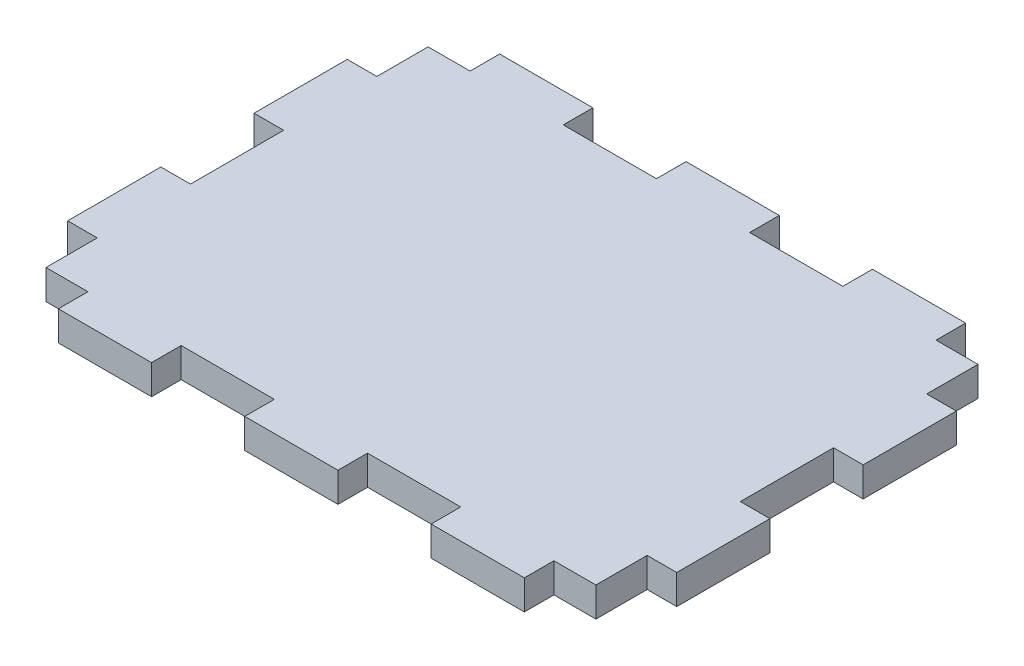
from build123d import *

# Parameters (mm, degrees)
SKETCH1_W           = 65.35
SKETCH1_H           = 47.35
BOSS_EXTRUDE1_DEPTH = 3.175
SKETCH2_W           = 4.5
SKETCH2_H           = 3.175
SKETCH2_W_2         = 3.175
SKETCH2_H_2         = 10
SKETCH2_W_3         = 10
CUT_EXTRUDE1_DEPTH  = 4.175


with BuildPart() as part:
    # Sketch1 → Boss-Extrude1 (new body)
    with BuildSketch(Plane(origin=(0, 0, 0), x_dir=(1, 0, 0), z_dir=(0, 1, 0))):
        with Locations((32.675, 23.675)):
            Rectangle(SKETCH1_W, SKETCH1_H)
    extrude(amount=BOSS_EXTRUDE1_DEPTH)

    # Sketch2 → Cut-Extrude1 (cut, through all)
    with BuildSketch(Plane.XZ):
        with Locations((59.925, -45.7625)):
            Rectangle(SKETCH2_W, SKETCH2_H)
        Polygon((65.35, -38.675), (62.175, -38.675), (62.175, -44.175), (62.175, -47.35), (65.35, -47.35), align=None)
        with Locations((63.7625, -23.675)):
            Rectangle(SKETCH2_W_2, SKETCH2_H_2)
        Polygon((62.175, -8.675), (65.35, -8.675), (65.35, 0), (62.175, 0), (62.175, -3.175), align=None)
        with Locations((59.925, -1.5875)):
            Rectangle(SKETCH2_W, SKETCH2_H)
        with Locations((42.675, -1.5875)):
            Rectangle(SKETCH2_W_3, SKETCH2_H)
        with Locations((42.675, -45.7625)):
            Rectangle(SKETCH2_W_3, SKETCH2_H)
        with Locations((22.675, -45.7625)):
            Rectangle(SKETCH2_W_3, SKETCH2_H)
        with Locations((5.425, -45.7625)):
            Rectangle(SKETCH2_W, SKETCH2_H)
        Polygon((0, -47.35), (3.175, -47.35), (3.175, -44.175), (3.175, -38.675), (0, -38.675), align=None)
        with Locations((1.5875, -23.675)):
            Rectangle(SKETCH2_W_2, SKETCH2_H_2)
        Polygon((3.175, -3.175), (3.175, 0), (0, 0), (0, -8.675), (3.175, -8.675), align=None)
        with Locations((5.425, -1.5875)):
            Rectangle(SKETCH2_W, SKETCH2_H)
        with Locations((22.675, -1.5875)):
            Rectangle(SKETCH2_W_3, SKETCH2_H)
    extrude(amount=-CUT_EXTRUDE1_DEPTH, mode=Mode.SUBTRACT)


solid = part.part
